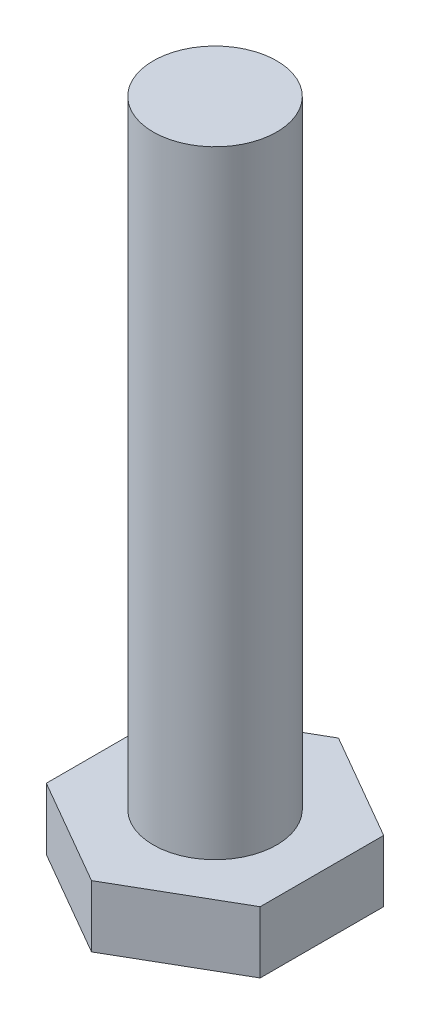
from build123d import *

# Parameters (mm, degrees)
SKETCH1_R           = 1
BOSS_EXTRUDE1_DEPTH = 0.5
SKETCH2_R           = 0.5
BOSS_EXTRUDE2_DEPTH = 5
SKETCH3_OUTSIDE_W   = 5.236
SKETCH3_OUTSIDE_H   = 5.236
CUT_EXTRUDE2_DEPTH  = 10


with BuildPart() as part:
    # Sketch1 → Boss-Extrude1 (new body)
    with BuildSketch(Plane(origin=(0, 0, 0), x_dir=(1, 0, 0), z_dir=(0, 1, 0))):
        Circle(SKETCH1_R)
    extrude(amount=BOSS_EXTRUDE1_DEPTH)

    # Sketch2 → Boss-Extrude2 (add)
    with BuildSketch(Plane(origin=(0, 0.5, 0), x_dir=(1, 0, 0), z_dir=(0, 1, 0))):
        Circle(SKETCH2_R)
    extrude(amount=BOSS_EXTRUDE2_DEPTH)

    # Sketch3 outside → Cut-Extrude2 (cut)
    with BuildSketch(Plane(origin=(0, 0, 0), x_dir=(-1, 0, 0), z_dir=(0, -1, 0))):
        Rectangle(SKETCH3_OUTSIDE_W, SKETCH3_OUTSIDE_H)
        Polygon((0.866025404, 0.5), (0, 1), (-0.866025404, 0.5), (-0.866025404, -0.5), (0, -1), (0.866025404, -0.5), align=None, mode=Mode.SUBTRACT)
    extrude(amount=-CUT_EXTRUDE2_DEPTH, mode=Mode.SUBTRACT)


solid = part.part
